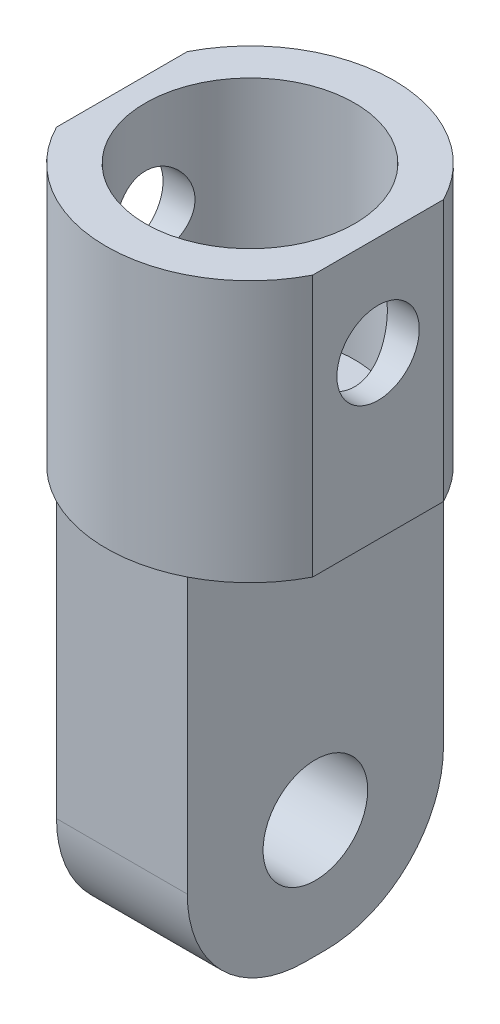
from build123d import *

# Parameters (mm, degrees)
SKETCH1_R           = 11
BOSS_EXTRUDE1_DEPTH = 20
SKETCH2_R           = 8
CUT_EXTRUDE1_DEPTH  = 17
SKETCH3_W           = 10
SKETCH3_H           = 19.595917942
BOSS_EXTRUDE2_DEPTH = 30
SKETCH4_R           = 4
CUT_EXTRUDE2_DEPTH  = 17
FILLET1_R           = 9
CUT_EXTRUDE3_DEPTH  = 51
SKETCH6_R           = 3.15
CUT_EXTRUDE4_DEPTH  = 20.595917942


with BuildPart() as part:
    # Sketch1 → Boss-Extrude1 (new body)
    with BuildSketch(Plane(origin=(0, 0, 0), x_dir=(1, 0, 0), z_dir=(0, 1, 0))):
        Circle(SKETCH1_R)
    extrude(amount=BOSS_EXTRUDE1_DEPTH)

    # Sketch2 → Cut-Extrude1 (cut)
    with BuildSketch(Plane(origin=(0, 20, 0), x_dir=(1, 0, 0), z_dir=(0, 1, 0))):
        Circle(SKETCH2_R)
    extrude(amount=-CUT_EXTRUDE1_DEPTH, mode=Mode.SUBTRACT)

    # Sketch3 → Boss-Extrude2 (add)
    with BuildSketch(Plane.XZ):
        Rectangle(SKETCH3_W, SKETCH3_H)
    extrude(amount=BOSS_EXTRUDE2_DEPTH)

    # Sketch4 → Cut-Extrude2 (cut, through all)
    with BuildSketch(Plane(origin=(5, 0, 0), x_dir=(0, 0, -1), z_dir=(1, 0, 0))):
        with Locations((0, -21)):
            Circle(SKETCH4_R)
    extrude(amount=-CUT_EXTRUDE2_DEPTH, mode=Mode.SUBTRACT)

    # Fillet1
    fillet1_edges = [part.edges().sort_by_distance(p)[0] for p in [
        (0, -30, 9.797958971),
        (0, -30, -9.797958971),
    ]]
    fillet(fillet1_edges, radius=FILLET1_R)

    # Sketch5 → Cut-Extrude3 (cut, through all)
    with BuildSketch(Plane(origin=(0, 20, 0), x_dir=(1, 0, 0), z_dir=(0, 1, 0))):
        with BuildLine():
            Line((-9.797958971, 5), (-9.797958971, -5))
            ThreePointArc((-9.797958971, -5), (-11, 0), (-9.797958971, 5))
        make_face()
        with BuildLine():
            Line((9.797958971, -5), (9.797958971, 5))
            ThreePointArc((9.797958971, 5), (11, 0), (9.797958971, -5))
        make_face()
    extrude(amount=-CUT_EXTRUDE3_DEPTH, mode=Mode.SUBTRACT)

    # Sketch6 → Cut-Extrude4 (cut, through all)
    with BuildSketch(Plane.ZY.offset(9.797958971)):
        with Locations((0, 12.35)):
            Circle(SKETCH6_R)
    extrude(amount=-CUT_EXTRUDE4_DEPTH, mode=Mode.SUBTRACT)


solid = part.part
